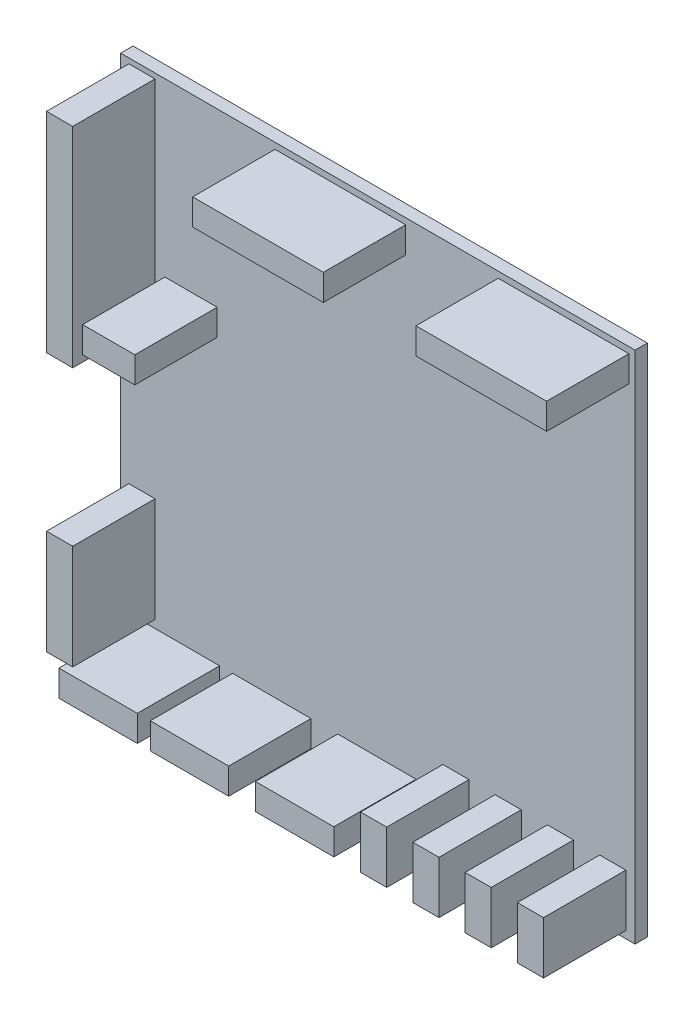
from build123d import *

# Parameters (mm, degrees)
CROQUIS1_W              = 50
CROQUIS1_H              = 50
SALIENTE_EXTRUIR1_DEPTH = 1.2
CROQUIS2_W              = 12.7
CROQUIS2_H              = 2.54
CROQUIS2_W_2            = 2.54
CROQUIS2_H_2            = 20.32
CROQUIS2_W_3            = 5.08
CROQUIS2_H_3            = 10.16
CROQUIS2_W_4            = 7.62
CROQUIS2_H_4            = 5.08
SALIENTE_EXTRUIR2_DEPTH = 8


with BuildPart() as part:
    # Croquis1 → Saliente-Extruir1 (new body)
    with BuildSketch(Plane.XY):
        with Locations((25, 25)):
            Rectangle(CROQUIS1_W, CROQUIS1_H)
    extrude(amount=SALIENTE_EXTRUIR1_DEPTH)

    # Croquis2 → Saliente-Extruir2 (add)
    with BuildSketch(Plane.XY.offset(1.2)):
        with Locations((43.05, 48.13)):
            Rectangle(CROQUIS2_W, CROQUIS2_H)
        with Locations((21.35, 48.13)):
            Rectangle(CROQUIS2_W, CROQUIS2_H)
        with Locations((2.07, 39.34)):
            Rectangle(CROQUIS2_W_2, CROQUIS2_H_2)
        with Locations((6.84, 32.03)):
            Rectangle(CROQUIS2_W_3, CROQUIS2_H)
        with Locations((2.07, 9.08)):
            Rectangle(CROQUIS2_W_2, CROQUIS2_H_3)
        with Locations((5.81, 1.97)):
            Rectangle(CROQUIS2_W_4, CROQUIS2_H)
        with Locations((14.69, 1.97)):
            Rectangle(CROQUIS2_W_4, CROQUIS2_H)
        with Locations((24.91, 1.97)):
            Rectangle(CROQUIS2_W_4, CROQUIS2_H)
        with Locations((32.59, 3.24)):
            Rectangle(CROQUIS2_W_2, CROQUIS2_H_4)
        with Locations((37.67, 3.24)):
            Rectangle(CROQUIS2_W_2, CROQUIS2_H_4)
        with Locations((42.75, 3.24)):
            Rectangle(CROQUIS2_W_2, CROQUIS2_H_4)
        with Locations((47.83, 3.24)):
            Rectangle(CROQUIS2_W_2, CROQUIS2_H_4)
    extrude(amount=SALIENTE_EXTRUIR2_DEPTH)


solid = part.part
